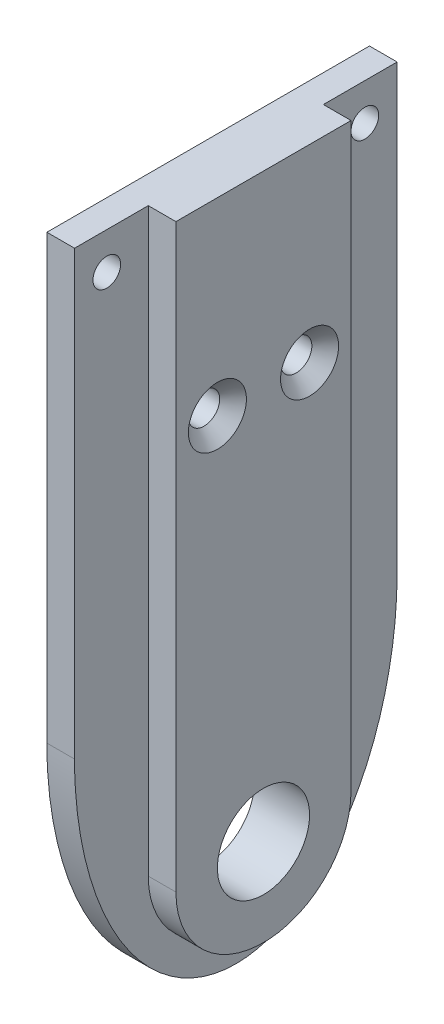
from build123d import *

# Parameters (mm, degrees)
BOSS_EXTRUDE1_DEPTH                             = 6
CUT_EXTRUDE1_DEPTH                              = 3
F_3_0MM_DOWEL_HOLE1_D                           = 3
CUT_EXTRUDE2_DEPTH                              = 3
CSK_FOR_M3_FLAT_HEAD_MACHINE_SCREW1_D           = 3.4
CSK_FOR_M3_FLAT_HEAD_MACHINE_SCREW1_CSINK_D     = 6.3
CSK_FOR_M3_FLAT_HEAD_MACHINE_SCREW1_CSINK_ANGLE = 90
SKETCH9_R                                       = 5
CUT_EXTRUDE3_DEPTH                              = 6


with BuildPart() as part:
    # Sketch1 → Boss-Extrude1 (new body)
    with BuildSketch(Plane(origin=(0, 0, 0), x_dir=(0, 0, -1), z_dir=(1, 0, 0))):
        with BuildLine():
            Line((-17.5, 63), (-17.5, 0))
            ThreePointArc((-17.5, 0), (0, -17.5), (17.5, 0))
            Line((17.5, 0), (17.5, 63))
            Line((17.5, 63), (-17.5, 63))
        make_face()
    extrude(amount=BOSS_EXTRUDE1_DEPTH)

    # Sketch5 → Cut-Extrude1 (cut)
    with BuildSketch(Plane(origin=(6, 0, 0), x_dir=(0, 0, -1), z_dir=(1, 0, 0))):
        with BuildLine():
            Line((-9.5, 63), (-9.5, 0))
            ThreePointArc((-9.5, 0), (0, -9.5), (9.5, 0))
            Line((9.5, 0), (9.5, 63))
            Line((9.5, 63), (17.5, 63))
            Line((17.5, 63), (17.5, 0))
            ThreePointArc((17.5, 0), (0, -17.5), (-17.5, 0))
            Line((-17.5, 0), (-17.5, 63))
            Line((-17.5, 63), (-9.5, 63))
        make_face()
    extrude(amount=-CUT_EXTRUDE1_DEPTH, mode=Mode.SUBTRACT)

    # Ø3.0mm Dowel Hole1 (through all)
    with Locations(Plane(origin=(3, 0, 0), x_dir=(0, 0, 1), z_dir=(1, 0, 0))):
        with Locations((-14, -59), (14, -59)):
            Hole(F_3_0MM_DOWEL_HOLE1_D / 2)

    # Sketch6 → Cut-Extrude2 (cut)
    with BuildSketch(Plane(origin=(3, 0, 0), x_dir=(0, 0, -1), z_dir=(1, 0, 0))):
        with BuildLine():
            Line((-17.5, 15), (-17.5, 0))
            ThreePointArc((-17.5, 0), (0, -17.5), (17.5, 0))
            Line((17.5, 0), (17.5, 15))
            add(Edge.make_bspline(
                [(-17.5, 15), (-17.5, -13), (0, -13), (17.5, -13), (17.5, 15)],
                knots=[1.570796327, 1.570796327, 1.570796327, 3.141592654, 3.141592654, 4.71238898, 4.71238898, 4.71238898], degree=2, weights=[1, 0.707106781, 1, 0.707106781, 1]))
        make_face()
    extrude(amount=-CUT_EXTRUDE2_DEPTH, mode=Mode.SUBTRACT)

    # CSK for M3 Flat Head Machine Screw1 (through all)
    with Locations(Plane(origin=(6, 0, 0), x_dir=(0, 0, -1), z_dir=(1, 0, 0))):
        with Locations((-5, 42.5), (5, 42.5)):
            CounterSinkHole(CSK_FOR_M3_FLAT_HEAD_MACHINE_SCREW1_D / 2, CSK_FOR_M3_FLAT_HEAD_MACHINE_SCREW1_CSINK_D / 2, counter_sink_angle=CSK_FOR_M3_FLAT_HEAD_MACHINE_SCREW1_CSINK_ANGLE)

    # Sketch9 → Cut-Extrude3 (cut)
    with BuildSketch(Plane(origin=(6, 0, 0), x_dir=(0, 0, -1), z_dir=(1, 0, 0))):
        Circle(SKETCH9_R)
    extrude(amount=-CUT_EXTRUDE3_DEPTH, mode=Mode.SUBTRACT)


solid = part.part
